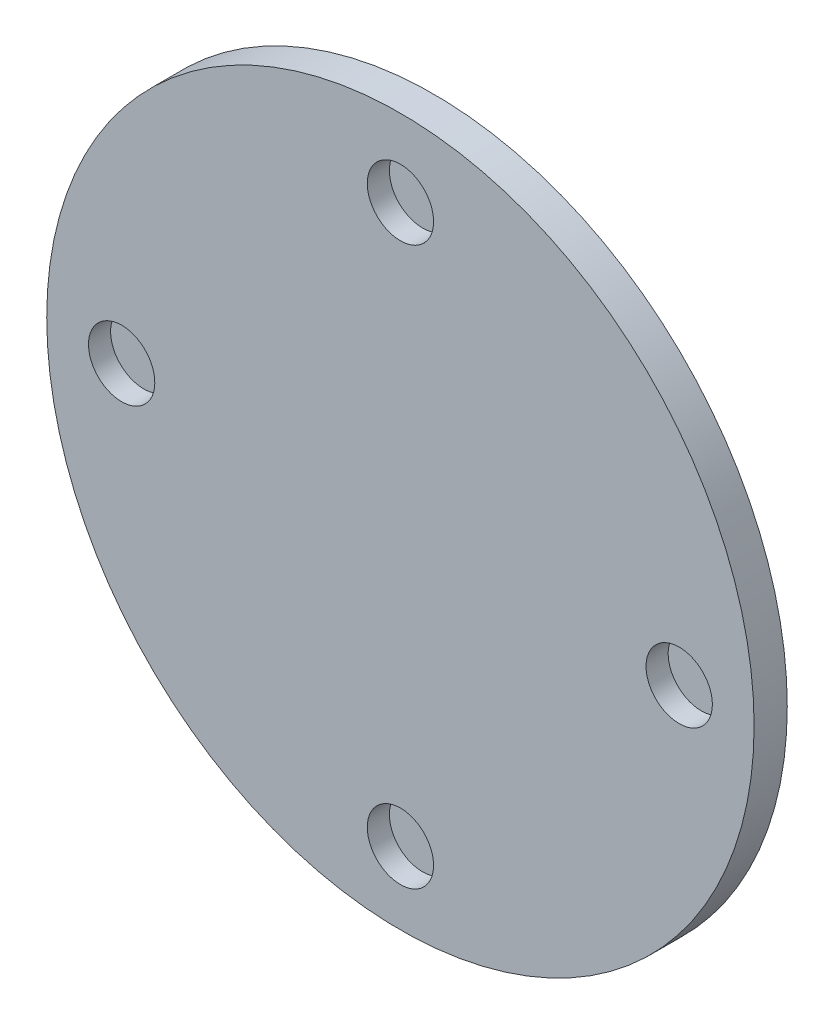
from build123d import *

# Parameters (mm, degrees)
SCHIZZO1_R                   = 16
ESTRUSIONE_ESTRUSIONE1_DEPTH = 1.5
SCHIZZO7_R                   = 1.5
TAGLIO_ESTRUSIONE1_DEPTH     = 1
RIPETIZIONECIRCOLARE1_COUNT  = 4


with BuildPart() as part:
    # Schizzo1 → Estrusione-Estrusione1 (new body)
    with BuildSketch(Plane.XY):
        Circle(SCHIZZO1_R)
    extrude(amount=-ESTRUSIONE_ESTRUSIONE1_DEPTH)

    # Schizzo7 → Taglio-Estrusione1 (cut)
    with BuildSketch(Plane.XY):
        with Locations((0, 12.5)):
            Circle(SCHIZZO7_R)
    taglio_estrusione1 = extrude(amount=-TAGLIO_ESTRUSIONE1_DEPTH, mode=Mode.SUBTRACT)

    # RipetizioneCircolare1: Taglio-Estrusione1 ×4 about axis
    ripetizionecircolare1_axis = Axis((0, -0.110837438, 0), (0, 0, 1))
    for i in range(1, RIPETIZIONECIRCOLARE1_COUNT):
        add(taglio_estrusione1.rotate(ripetizionecircolare1_axis, i * 360 / RIPETIZIONECIRCOLARE1_COUNT), mode=Mode.SUBTRACT)


solid = part.part
